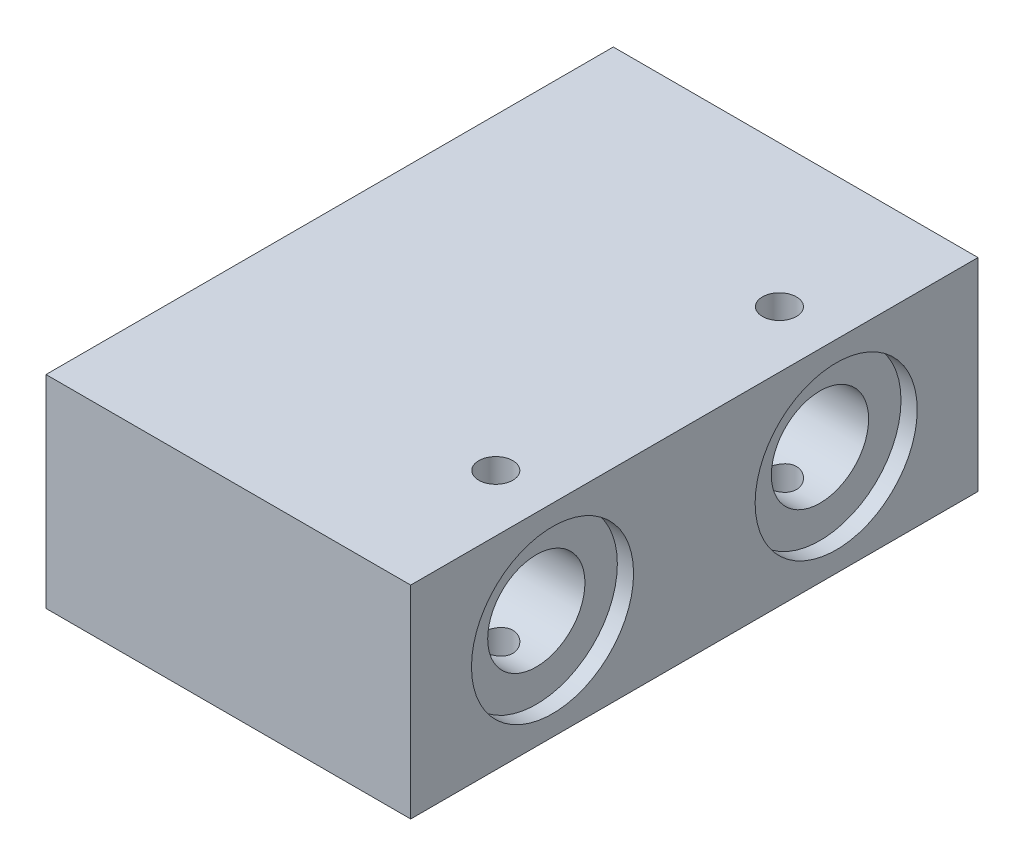
from build123d import *

# Parameters (mm, degrees)
SKETCH1_W                = 45
SKETCH1_H                = 102
BOSS_EXTRUDE1_DEPTH      = 25
M5_TAPPED_HOLE3_D        = 4.2
SKETCH27_R               = 6
CUT_EXTRUDE1_DEPTH       = 74
SKETCH28_R               = 10
CUT_EXTRUDE3_DEPTH       = 2
SKETCH30_R               = 10
CUT_EXTRUDE4_DEPTH       = 2
M5_TAPPED_HOLE4_D        = 4.2
M5_TAPPED_HOLE4_DEPTH    = 14
M5_TAPPED_HOLE4_TIP      = 1.2618073
M5_TAPPED_HOLE5_D        = 4.2
M5_TAPPED_HOLE5_DEPTH    = 15
M5_TAPPED_HOLE5_TIP      = 1.2618073
CUT_EXTRUDE5_DEPTH       = 1.0000001
CUT_EXTRUDE5_DEPTH_BACK  = 26.0000001
CUT_EXTRUDE12_DEPTH      = 1.0000001
CUT_EXTRUDE12_DEPTH_BACK = 26.0000001
M5_TAPPED_HOLE6_D        = 4.2
M5_TAPPED_HOLE6_DEPTH    = 15
M5_TAPPED_HOLE6_TIP      = 1.2618073


with BuildPart() as part:
    # Sketch1 → Boss-Extrude1 (new body)
    with BuildSketch(Plane(origin=(0, 0, 0), x_dir=(1, 0, 0), z_dir=(0, 1, 0))):
        Rectangle(SKETCH1_W, SKETCH1_H)
    extrude(amount=BOSS_EXTRUDE1_DEPTH)

    # M5 Tapped Hole3 (through all)
    with Locations(Plane(origin=(0, 25, 0), x_dir=(1, 0, 0), z_dir=(0, 1, 0))):
        with Locations((15.5, 17.5), (15.5, -17.5)):
            Hole(M5_TAPPED_HOLE3_D / 2)

    # Sketch27 → Cut-Extrude1 (cut)
    with BuildSketch(Plane.ZY.offset(22.5)):
        with Locations((-17.5, 12.5)):
            Circle(SKETCH27_R)
        with Locations((17.5, 12.5)):
            Circle(SKETCH27_R)
    extrude(amount=-CUT_EXTRUDE1_DEPTH, mode=Mode.SUBTRACT)

    # Sketch28 → Cut-Extrude3 (cut)
    with BuildSketch(Plane.ZY.offset(22.5)):
        with Locations((-17.5, 12.5)):
            Circle(SKETCH28_R)
        with Locations((17.5, 12.5)):
            Circle(SKETCH28_R)
    extrude(amount=-CUT_EXTRUDE3_DEPTH, mode=Mode.SUBTRACT)

    # Sketch30 → Cut-Extrude4 (cut)
    with BuildSketch(Plane(origin=(22.5, 0, 0), x_dir=(0, 0, -1), z_dir=(1, 0, 0))):
        with Locations((-17.5, 12.5)):
            Circle(SKETCH30_R)
        with Locations((17.5, 12.5)):
            Circle(SKETCH30_R)
    extrude(amount=-CUT_EXTRUDE4_DEPTH, mode=Mode.SUBTRACT)

    # M5 Tapped Hole4
    with Locations(Plane(origin=(0, 0, -51), x_dir=(-1, 0, 0), z_dir=(0, 0, -1))):
        with Locations((-18, 5), (18, 20)):
            Hole(M5_TAPPED_HOLE4_D / 2, depth=M5_TAPPED_HOLE4_DEPTH)
            with Locations((0, 0, -(M5_TAPPED_HOLE4_DEPTH + M5_TAPPED_HOLE4_TIP / 2))):  # 118° drill point
                Cone(0, M5_TAPPED_HOLE4_D / 2, M5_TAPPED_HOLE4_TIP, mode=Mode.SUBTRACT)

    # M5 Tapped Hole5
    with Locations(Plane.ZY.offset(22.5)):
        with Locations((0, 12.5)):
            Hole(M5_TAPPED_HOLE5_D / 2, depth=M5_TAPPED_HOLE5_DEPTH)
            with Locations((0, 0, -(M5_TAPPED_HOLE5_DEPTH + M5_TAPPED_HOLE5_TIP / 2))):  # 118° drill point
                Cone(0, M5_TAPPED_HOLE5_D / 2, M5_TAPPED_HOLE5_TIP, mode=Mode.SUBTRACT)

    # Sketch37 → Cut-Extrude5 (cut, two sides)
    with BuildSketch(Plane(origin=(0, 25, 0), x_dir=(1, 0, 0), z_dir=(0, 1, 0))) as cut_extrude5_sk:
        Polygon((-226.623671921, 35), (-22.5, 35), (22.5, 35), (226.623671921, 35), (226.623671921, 443.247343842), (-226.623671921, 443.247343842), align=None)
    extrude(amount=CUT_EXTRUDE5_DEPTH, mode=Mode.SUBTRACT)
    extrude(cut_extrude5_sk.sketch, amount=-CUT_EXTRUDE5_DEPTH_BACK, mode=Mode.SUBTRACT)

    # Sketch38 → Cut-Extrude12 (cut, two sides)
    with BuildSketch(Plane(origin=(0, 25, 0), x_dir=(1, 0, 0), z_dir=(0, 1, 0))) as cut_extrude12_sk:
        Polygon((-198.933169771, -35), (-22.5, -35), (22.5, -35), (198.933169771, -35), (198.933169771, -387.866339542), (-198.933169771, -387.866339542), align=None)
    extrude(amount=CUT_EXTRUDE12_DEPTH, mode=Mode.SUBTRACT)
    extrude(cut_extrude12_sk.sketch, amount=-CUT_EXTRUDE12_DEPTH_BACK, mode=Mode.SUBTRACT)

    # M5 Tapped Hole6
    with Locations(Plane.ZY.offset(22.5)):
        with Locations((-29, 5), (29, 20)):
            Hole(M5_TAPPED_HOLE6_D / 2, depth=M5_TAPPED_HOLE6_DEPTH)
            with Locations((0, 0, -(M5_TAPPED_HOLE6_DEPTH + M5_TAPPED_HOLE6_TIP / 2))):  # 118° drill point
                Cone(0, M5_TAPPED_HOLE6_D / 2, M5_TAPPED_HOLE6_TIP, mode=Mode.SUBTRACT)


solid = part.part
